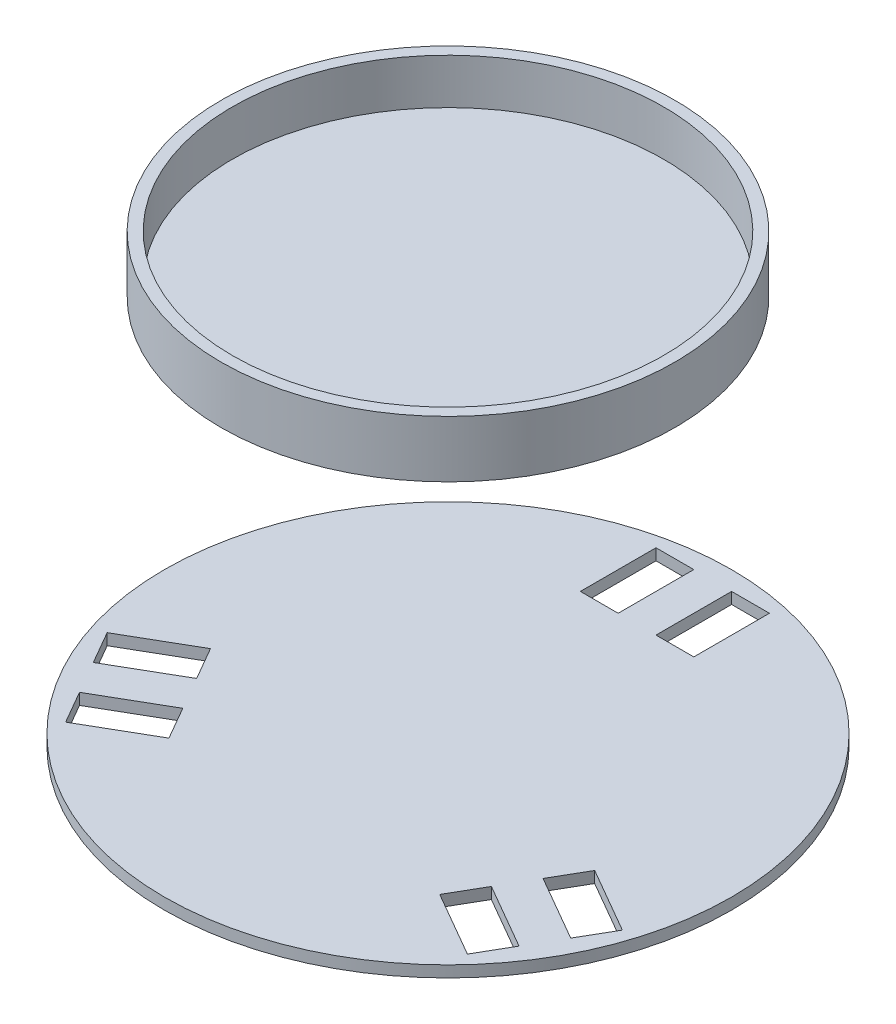
from build123d import *

# Parameters (mm, degrees)
SKETCH1_R           = 150
BOSS_EXTRUDE1_DEPTH = 6
SKETCH2_W           = 20
SKETCH2_H           = 40
CUT_EXTRUDE1_DEPTH  = 6
SKETCH3_R           = 120
BOSS_EXTRUDE2_DEPTH = 6
SKETCH5_R           = 120
SKETCH5_R_2         = 114
BOSS_EXTRUDE4_DEPTH = 24


with BuildPart() as part:
    # Sketch1 → Boss-Extrude1 (new body)
    with BuildSketch(Plane(origin=(0, 0, 0), x_dir=(1, 0, 0), z_dir=(0, 1, 0))):
        with Locations(Location((0, 0, 0), (0, 0, 270))):  # turned: the seam where the file's is
            Circle(SKETCH1_R)
    extrude(amount=BOSS_EXTRUDE1_DEPTH)

    # Sketch2 → Cut-Extrude1 (cut)
    with BuildSketch(Plane(origin=(0, 6, 0), x_dir=(1, 0, 0), z_dir=(0, 1, 0))):
        with Locations((-20, 120)):
            Rectangle(SKETCH2_W, SKETCH2_H)
        with Locations((20, 120)):
            Rectangle(SKETCH2_W, SKETCH2_H)
        Polygon((126.24355653, -61.339745962), (91.602540378, -41.339745962), (101.602540378, -24.019237886), (136.24355653, -44.019237886), align=None)
        Polygon((116.24355653, -78.660254038), (81.602540378, -58.660254038), (71.602540378, -75.980762114), (106.24355653, -95.980762114), align=None)
        Polygon((-116.24355653, -78.660254038), (-81.602540378, -58.660254038), (-71.602540378, -75.980762114), (-106.24355653, -95.980762114), align=None)
        Polygon((-126.24355653, -61.339745962), (-91.602540378, -41.339745962), (-101.602540378, -24.019237886), (-136.24355653, -44.019237886), align=None)
    extrude(amount=-CUT_EXTRUDE1_DEPTH, mode=Mode.SUBTRACT)


with BuildPart() as body_2:
    # Sketch3 → Boss-Extrude2 (new body)
    with BuildSketch(Plane(origin=(0, 206, 0), x_dir=(1, 0, 0), z_dir=(0, 1, 0))):
        with Locations(Location((0, 0, 0), (0, 0, 270))):  # turned: the seam where the file's is
            Circle(SKETCH3_R)
    extrude(amount=BOSS_EXTRUDE2_DEPTH)

    # Sketch5 → Boss-Extrude4 (add)
    with BuildSketch(Plane(origin=(0, 212, 0), x_dir=(1, 0, 0), z_dir=(0, 1, 0))):
        with Locations(Location((0, 0, 0), (0, 0, 270))):  # turned: the seam where the file's is
            Circle(SKETCH5_R)
        with Locations(Location((0, 0, 0), (0, 0, 270))):  # turned: the seam where the file's is
            Circle(SKETCH5_R_2, mode=Mode.SUBTRACT)
    extrude(amount=BOSS_EXTRUDE4_DEPTH)


solid = Compound([part.part, body_2.part])
